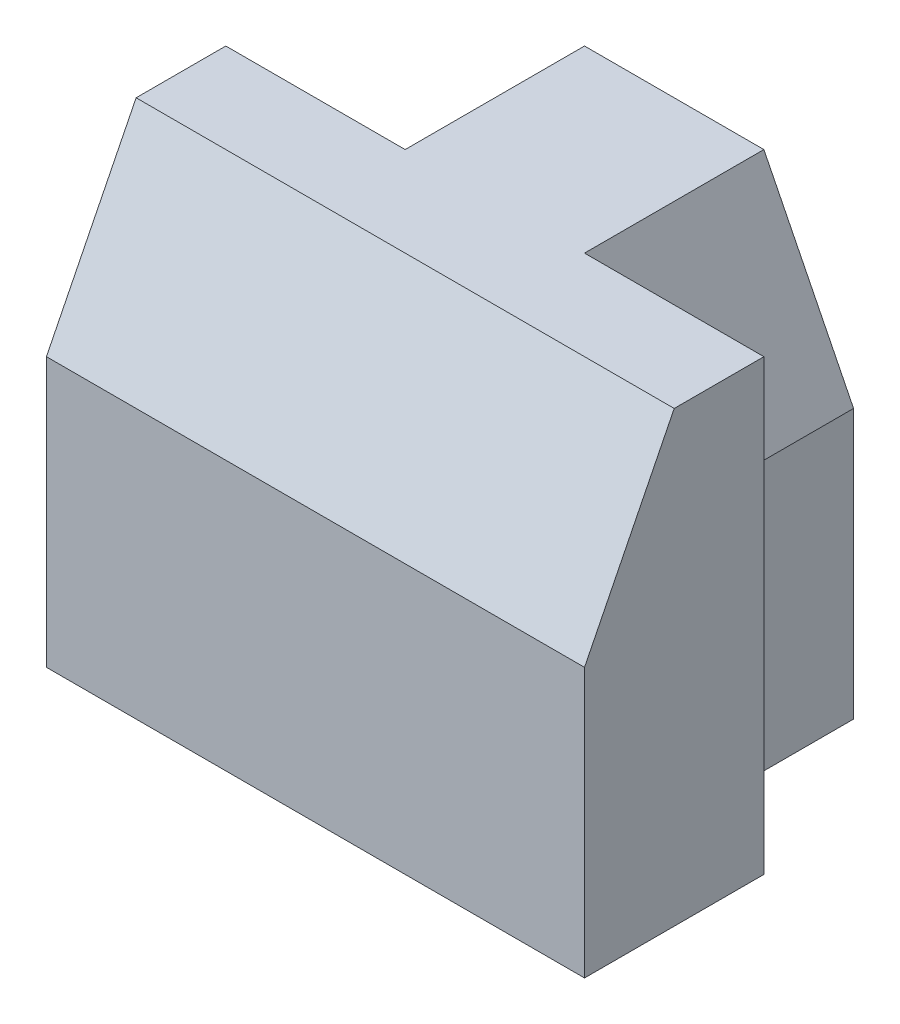
from build123d import *

# Parameters (mm, degrees)
SKETCH1_W           = 30
SKETCH1_H           = 25
BOSS_EXTRUDE1_DEPTH = 20
CUT_EXTRUDE1_DEPTH  = 50
CUT_EXTRUDE2_DEPTH  = 10


with BuildPart() as part:
    # Sketch1 → Boss-Extrude1 (new body)
    with BuildSketch(Plane.XY):
        with Locations((15, 12.5)):
            Rectangle(SKETCH1_W, SKETCH1_H)
    extrude(amount=BOSS_EXTRUDE1_DEPTH)

    # Sketch2 → Cut-Extrude1 (cut)
    with BuildSketch(Plane.ZY):
        Polygon((15, 25), (20, 15), (20, 25), align=None)
    extrude(amount=-CUT_EXTRUDE1_DEPTH, mode=Mode.SUBTRACT)

    # Sketch3 → Cut-Extrude2 (cut)
    with BuildSketch(Plane(origin=(0, 0, 0), x_dir=(-1, 0, 0), z_dir=(0, 0, -1))):
        Polygon((-20, 25), (-30, 25), (-30, 0), (-25, 0), (-25, 15), align=None)
        Polygon((0, 25), (-10, 25), (-5, 15), (-5, 0), (0, 0), align=None)
    extrude(amount=-CUT_EXTRUDE2_DEPTH, mode=Mode.SUBTRACT)


solid = part.part
